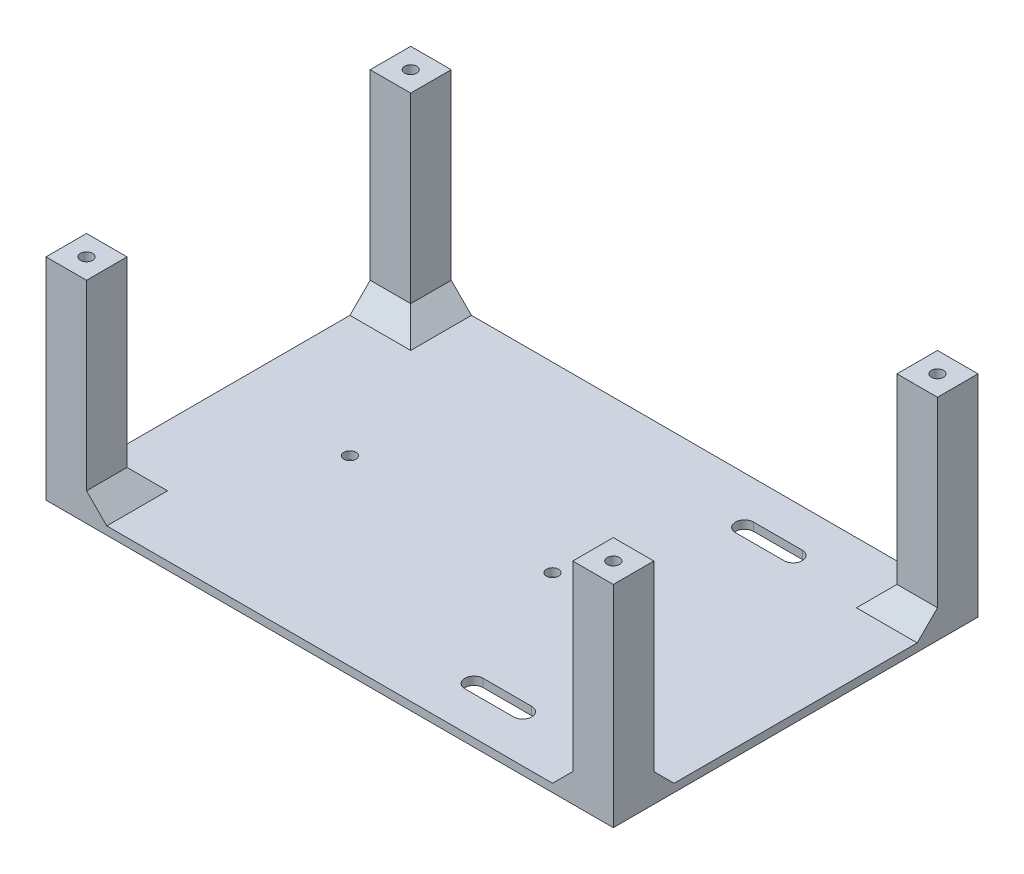
from build123d import *

# Parameters (mm, degrees)
SKETCH1_W           = 140
SKETCH1_H           = 90
BOSS_EXTRUDE1_DEPTH = 2
SKETCH2_W           = 10
SKETCH2_H           = 10
BOSS_EXTRUDE2_DEPTH = 50
CHAMFER1_SIZE       = 5
SKETCH3_R           = 1.5
CUT_EXTRUDE1_DEPTH  = 53
SKETCH4_R           = 1.5
CUT_EXTRUDE2_DEPTH  = 3
CUT_EXTRUDE3_DEPTH  = 3


with BuildPart() as part:
    # Sketch1 → Boss-Extrude1 (new body)
    with BuildSketch(Plane(origin=(0, 0, 0), x_dir=(1, 0, 0), z_dir=(0, 1, 0))):
        Rectangle(SKETCH1_W, SKETCH1_H)
    extrude(amount=BOSS_EXTRUDE1_DEPTH)

    # Sketch2 → Boss-Extrude2 (add)
    with BuildSketch(Plane(origin=(0, 2, 0), x_dir=(1, 0, 0), z_dir=(0, 1, 0))):
        with Locations((-65, 40)):
            Rectangle(SKETCH2_W, SKETCH2_H)
        with Locations((65, 40)):
            Rectangle(SKETCH2_W, SKETCH2_H)
        with Locations((65, -40)):
            Rectangle(SKETCH2_W, SKETCH2_H)
        with Locations((-65, -40)):
            Rectangle(SKETCH2_W, SKETCH2_H)
    extrude(amount=BOSS_EXTRUDE2_DEPTH)

    # Chamfer1
    chamfer1_edges = [part.edges().sort_by_distance(p)[0] for p in [
        (-65, 2, -35),
        (-60, 2, -40),
        (60, 2, -40),
        (65, 2, -35),
        (65, 2, 35),
        (60, 2, 40),
        (-60, 2, 40),
        (-65, 2, 35),
    ]]
    chamfer(chamfer1_edges, length=CHAMFER1_SIZE)

    # Sketch3 → Cut-Extrude1 (cut, through all)
    with BuildSketch(Plane(origin=(0, 52, 0), x_dir=(1, 0, 0), z_dir=(0, 1, 0))):
        with Locations((-65, 40)):
            Circle(SKETCH3_R)
        with Locations((65, 40)):
            Circle(SKETCH3_R)
        with Locations((65, -40)):
            Circle(SKETCH3_R)
        with Locations((-65, -40)):
            Circle(SKETCH3_R)
    extrude(amount=-CUT_EXTRUDE1_DEPTH, mode=Mode.SUBTRACT)

    # Sketch4 → Cut-Extrude2 (cut, through all)
    with BuildSketch(Plane(origin=(0, 2, 0), x_dir=(1, 0, 0), z_dir=(0, 1, 0))):
        with Locations((-40, 0)):
            Circle(SKETCH4_R)
        with Locations((10, 0)):
            Circle(SKETCH4_R)
    extrude(amount=-CUT_EXTRUDE2_DEPTH, mode=Mode.SUBTRACT)

    # Sketch5 → Cut-Extrude3 (cut, through all)
    with BuildSketch(Plane(origin=(0, 2, 0), x_dir=(1, 0, 0), z_dir=(0, 1, 0))):
        with BuildLine():
            Line((24, 35.63), (36, 35.63))
            ThreePointArc((36, 35.63), (38.25, 33.38), (36, 31.13))
            Line((36, 31.13), (24, 31.13))
            ThreePointArc((24, 31.13), (21.75, 33.38), (24, 35.63))
        make_face()
    cut_extrude3 = extrude(amount=-CUT_EXTRUDE3_DEPTH, mode=Mode.SUBTRACT)

    # Mirror1: Cut-Extrude3 across plane
    add(cut_extrude3.mirror(Plane.XY), mode=Mode.SUBTRACT)


solid = part.part
